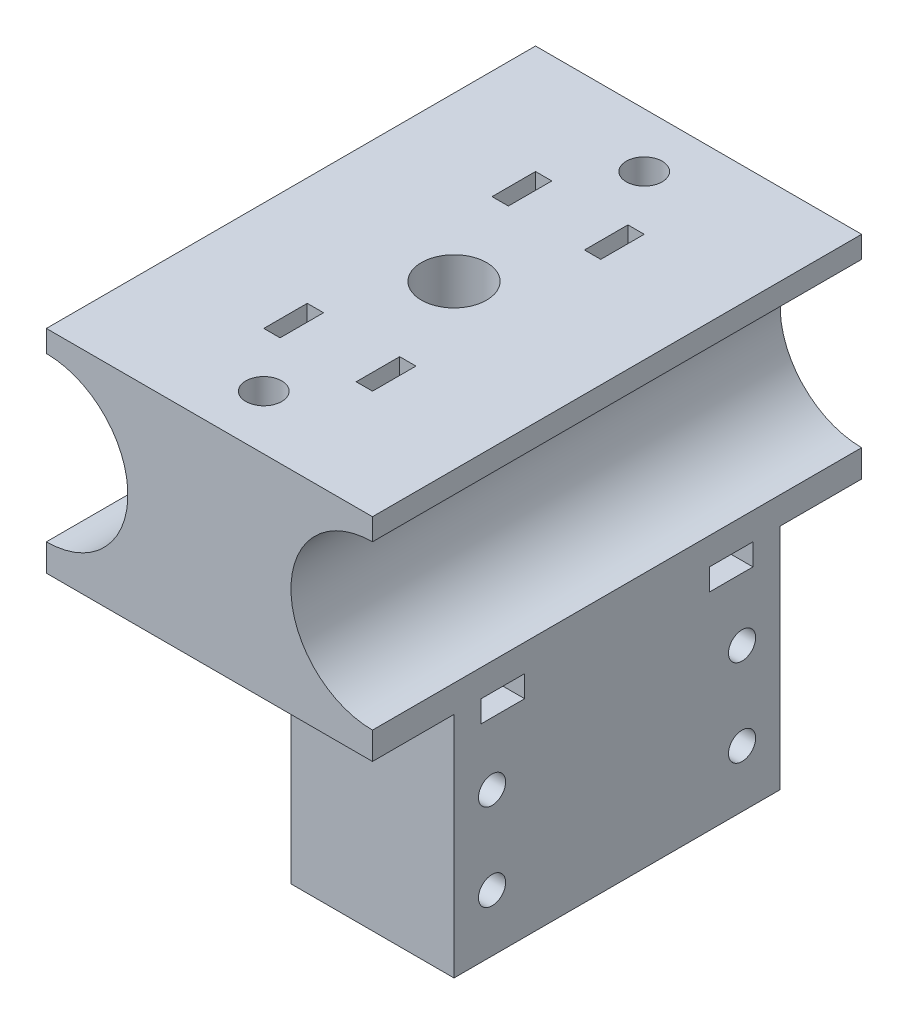
from build123d import *

# Parameters (mm, degrees)
BOSS_EXTRUDE1_DEPTH   = 22.5
M4X0_7_TAPPED_HOLE2_D = 3.3
REVOLVE1_ANGLE        = 180
BOSS_EXTRUDE4_REACH   = 42.5
M3X0_5_TAPPED_HOLE1_D = 2.5
SKETCH2_R             = 3
CUT_EXTRUDE1_DEPTH    = 50
CUT_EXTRUDE3_START    = -10
CUT_EXTRUDE3_DEPTH    = 4


with BuildPart() as part:
    # Sketch1 → Boss-Extrude1 (new body, symmetric)
    with BuildSketch(Plane.XY):
        with BuildLine():
            Line((-15, 7.5), (-15, 9.5))
            Line((-15, 9.5), (15, 9.5))
            Line((15, 9.5), (15, 7.5))
            ThreePointArc((15, 7.5), (7.5, 0), (15, -7.5))
            Line((15, -7.5), (15, -10))
            Line((15, -10), (-15, -10))
            Line((-15, -10), (-15, -7.5))
            ThreePointArc((-15, -7.5), (-7.5, 0), (-15, 7.5))
        make_face()
    extrude(amount=BOSS_EXTRUDE1_DEPTH, both=True)

    # M4x0.7 Tapped Hole2 (through all)
    with Locations(Plane(origin=(0, -10, 0), x_dir=(-1, 0, 0), z_dir=(0, -1, 0))):
        with Locations((0, -17.5), (0, 17.5)):
            Hole(M4X0_7_TAPPED_HOLE2_D / 2)

    # Sketch12 → Revolve1 (revolve, symmetric)
    with BuildSketch(Plane.XY) as revolve1_sk:
        Polygon((8, -31), (8, -24.5), (6, -24.5), (6, -19), (8, -19), (8, -10), (15, -10), (15, -31), align=None)
    revolve(axis=Axis((0, 0, 0), (0, -1, 0)), revolution_arc=REVOLVE1_ANGLE / 2)
    revolve(revolve1_sk.sketch, axis=Axis((0, 0, 0), (0, 1, 0)), revolution_arc=REVOLVE1_ANGLE / 2)

    # Sketch15 → Boss-Extrude4 (add, up to next)
    with BuildSketch(Plane.XZ.offset(31), mode=Mode.PRIVATE) as boss_extrude4_sk1:
        with BuildLine():
            Line((15, 15), (0, 15))
            ThreePointArc((0, 15), (10.606601729, 10.606601707), (15, -3.1e-08))
            Line((15, -3.1e-08), (15, 15))
        make_face()
    boss_extrude4_tool1 = extrude(boss_extrude4_sk1.sketch, amount=-BOSS_EXTRUDE4_REACH, mode=Mode.PRIVATE) - part.part
    add(boss_extrude4_tool1.solids().sort_by_distance((11.649481, -31, 11.649481))[0])
    # Sketch15 → Boss-Extrude4 (add, up to next)
    with BuildSketch(Plane.XZ.offset(31), mode=Mode.PRIVATE) as boss_extrude4_sk2:
        with BuildLine():
            Line((15, -15), (15, -3.1e-08))
            ThreePointArc((15, -3.1e-08), (10.606601707, -10.606601729), (0, -15))
            Line((0, -15), (15, -15))
        make_face()
    boss_extrude4_tool2 = extrude(boss_extrude4_sk2.sketch, amount=-BOSS_EXTRUDE4_REACH, mode=Mode.PRIVATE) - part.part
    add(boss_extrude4_tool2.solids().sort_by_distance((11.649481, -31, -11.649481))[0])

    # M3x0.5 Tapped Hole1 (through all)
    with Locations(Plane.ZY):
        with Locations((-11.5, -17.75), (-11.5, -25.75), (11.5, -25.75), (11.5, -17.75)):
            Hole(M3X0_5_TAPPED_HOLE1_D / 2)

    # Sketch2 → Cut-Extrude1 (cut)
    with BuildSketch(Plane(origin=(0, 9.5, 0), x_dir=(1, 0, 0), z_dir=(0, 1, 0))):
        Circle(SKETCH2_R)
    extrude(amount=-CUT_EXTRUDE1_DEPTH, mode=Mode.SUBTRACT)

    # Sketch11 → Cut-Extrude3 (cut)
    with BuildSketch(Plane(origin=(0, 0, -22.5), x_dir=(-1, 0, 0), z_dir=(0, 0, -1)).offset(CUT_EXTRUDE3_START)):
        with BuildLine():
            Line((-5, 9.5), (-5, 0))
            ThreePointArc((-5, 0), (-7.928932188, -7.071067812), (-15, -10))
            Line((-15, -10), (-15, -12))
            Line((-15, -12), (-3.5, -12))
            Line((-3.5, -12), (-3.5, -10))
            Line((-3.5, -10), (-3.5, 9.5))
            Line((-3.5, 9.5), (-5, 9.5))
        make_face()
        with BuildLine():
            Line((3.5, 9.5), (5, 9.5))
            Line((5, 9.5), (5, 0))
            ThreePointArc((5, 0), (7.928932188, -7.071067812), (15, -10))
            Line((15, -10), (15, -12))
            Line((15, -12), (3.5, -12))
            Line((3.5, -12), (3.5, -10))
            Line((3.5, -10), (3.5, 9.5))
        make_face()
    cut_extrude3 = extrude(amount=-CUT_EXTRUDE3_DEPTH, mode=Mode.SUBTRACT)

    # Mirror1: Cut-Extrude3 across plane
    add(cut_extrude3.mirror(Plane.XY), mode=Mode.SUBTRACT)


solid = part.part
